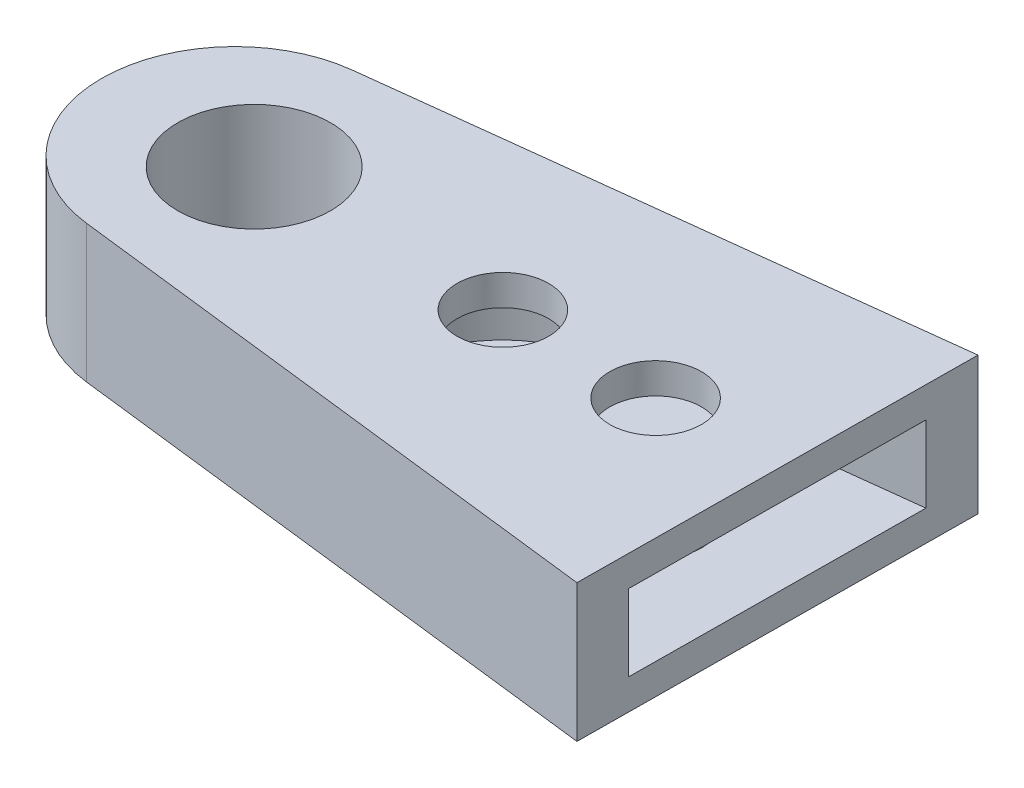
from build123d import *

# Parameters (mm, degrees)
BOSS_EXTRUDE1_DEPTH = 18
CUT_EXTRUDE1_DEPTH  = 14
SKETCH5_W           = 38.6
SKETCH5_H           = 4
BOSS_EXTRUDE2_DEPTH = 51.5
SKETCH6_R           = 10
CUT_EXTRUDE2_DEPTH  = 200
SKETCH7_R           = 6
CUT_EXTRUDE3_DEPTH  = 200


with BuildPart() as part:
    # Sketch2 → Boss-Extrude1 (new body)
    with BuildSketch(Plane(origin=(0, 0, 0), x_dir=(1, 0, 0), z_dir=(0, 1, 0))):
        with BuildLine():
            Line((-2.050203312, 17.379489819), (71.229085812, 26.024015225))
            Line((71.229085812, 26.024015225), (70.776256856, -26.027550211))
            Line((70.776256856, -26.027550211), (-2.063605293, -17.37790359))
            ThreePointArc((-2.063605293, -17.37790359), (-17.499998699, 0.006747763), (-2.050203312, 17.379489819))
        make_face()
    extrude(amount=BOSS_EXTRUDE1_DEPTH)

    # Sketch4 → Cut-Extrude1 (cut)
    with BuildSketch(Plane(origin=(0, 18, 0), x_dir=(1, 0, 0), z_dir=(0, 1, 0))):
        with BuildLine():
            Line((35.006766585, 14.999998474), (31.502988077, 14.586668832))
            ThreePointArc((31.502988077, 14.586668832), (20.004544926, -0.369225031), (32.22510993, -14.741098504))
            Line((32.22510993, -14.741098504), (34.245425362, -14.981008548))
            Line((34.245425362, -14.981008548), (70.834558469, -19.325924398))
            Line((70.834558469, -19.325924398), (71.170294461, 19.266095201))
            Line((71.170294461, 19.266095201), (35.006766585, 14.999998474))
        make_face()
    extrude(amount=-CUT_EXTRUDE1_DEPTH, mode=Mode.SUBTRACT)

    # Sketch5 → Boss-Extrude2 (add)
    with BuildSketch(Plane(origin=(70.997313391, 0, 0.617649806), x_dir=(0.008699293, 0, -0.99996216), z_dir=(0.99996216, 0, 0.008699293))):
        with Locations((0.591017469, 16)):
            Rectangle(SKETCH5_W, SKETCH5_H)
    extrude(amount=-BOSS_EXTRUDE2_DEPTH)

    # Sketch6 → Cut-Extrude2 (cut)
    with BuildSketch(Plane(origin=(0, 18, 0), x_dir=(1, 0, 0), z_dir=(0, 1, 0))):
        with Locations((2.500001301, 0)):
            Circle(SKETCH6_R)
    extrude(amount=-CUT_EXTRUDE2_DEPTH, mode=Mode.SUBTRACT)

    # Sketch7 → Cut-Extrude3 (cut)
    with BuildSketch(Plane(origin=(0, 18, 0), x_dir=(1, 0, 0), z_dir=(0, 1, 0))):
        with Locations((35.001789275, 0.053432271)):
            Circle(SKETCH7_R)
        with Locations((55.001789275, 0.053432271)):
            Circle(SKETCH7_R)
    extrude(amount=-CUT_EXTRUDE3_DEPTH, mode=Mode.SUBTRACT)


solid = part.part
